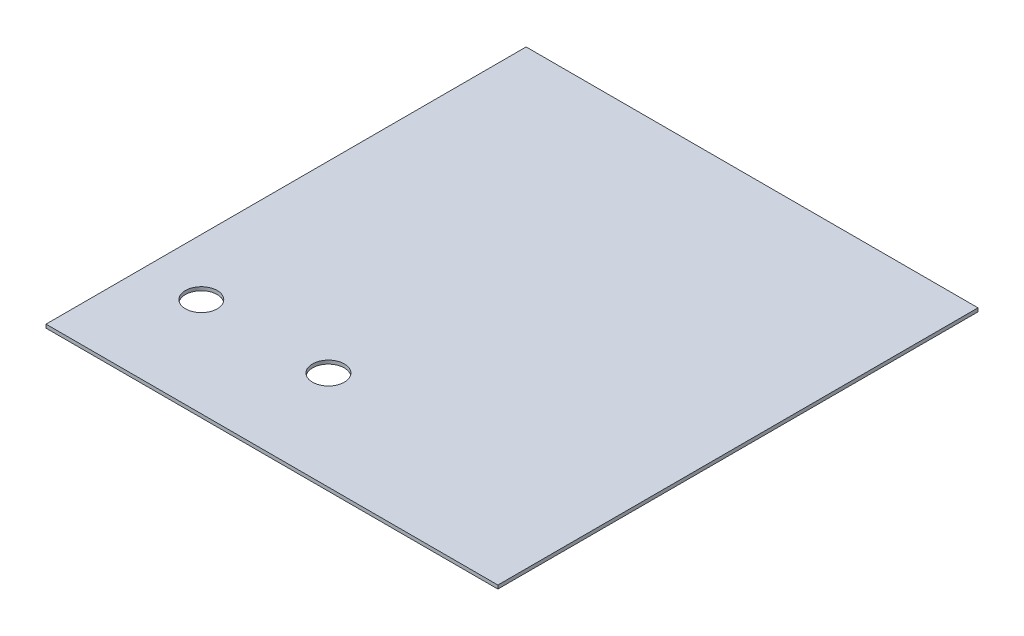
from build123d import *

# Parameters (mm, degrees)
SKETCH1_W           = 406.4
SKETCH1_H           = 431.8
BOSS_EXTRUDE1_DEPTH = 3.175
SKETCH2_R           = 14.2875
CUT_EXTRUDE1_DEPTH  = 3.175


with BuildPart() as part:
    # Sketch1 → Boss-Extrude1 (new body)
    with BuildSketch(Plane(origin=(0, 0, 0), x_dir=(1, 0, 0), z_dir=(0, 1, 0))):
        with Locations((203.2, 215.9)):
            Rectangle(SKETCH1_W, SKETCH1_H)
    extrude(amount=BOSS_EXTRUDE1_DEPTH)

    # Sketch2 → Cut-Extrude1 (cut)
    with BuildSketch(Plane(origin=(0, 3.175, 0), x_dir=(1, 0, 0), z_dir=(0, 1, 0))):
        with Locations((50.8, 88.9)):
            Circle(SKETCH2_R)
        with Locations((165.1, 88.9)):
            Circle(SKETCH2_R)
    extrude(amount=-CUT_EXTRUDE1_DEPTH, mode=Mode.SUBTRACT)


solid = part.part
